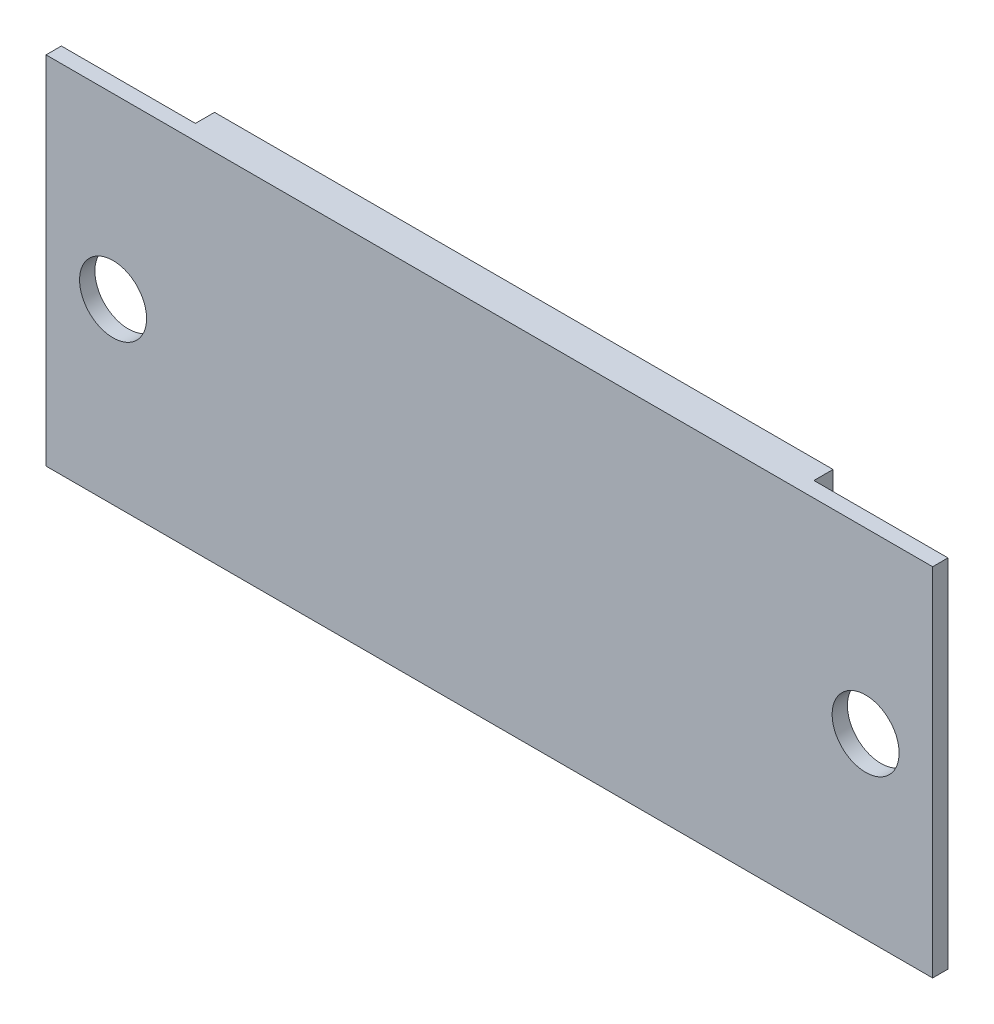
from build123d import *

# Parameters (mm, degrees)
SKETCH1_W           = 32.3
SKETCH1_H           = 18.6
BOSS_EXTRUDE1_DEPTH = 1.8
SKETCH5_W           = 7
SKETCH5_H           = 18.6
BOSS_EXTRUDE3_DEPTH = 0.8
SKETCH6_R           = 1.75
CUT_EXTRUDE3_DEPTH  = 0.8


with BuildPart() as part:
    # Sketch1 → Boss-Extrude1 (new body)
    with BuildSketch(Plane.XY):
        Rectangle(SKETCH1_W, SKETCH1_H)
    extrude(amount=BOSS_EXTRUDE1_DEPTH)

    # Sketch5 → Boss-Extrude3 (add)
    with BuildSketch(Plane.XY.offset(1.8)):
        with Locations((-19.65, 0)):
            Rectangle(SKETCH5_W, SKETCH5_H)
        with Locations((19.65, 0)):
            Rectangle(SKETCH5_W, SKETCH5_H)
    extrude(amount=-BOSS_EXTRUDE3_DEPTH)

    # Sketch6 → Cut-Extrude3 (cut)
    with BuildSketch(Plane.XY.offset(1.8)):
        with Locations((-19.65, 0)):
            Circle(SKETCH6_R)
        with Locations((19.65, 0)):
            Circle(SKETCH6_R)
    extrude(amount=-CUT_EXTRUDE3_DEPTH, mode=Mode.SUBTRACT)


solid = part.part
